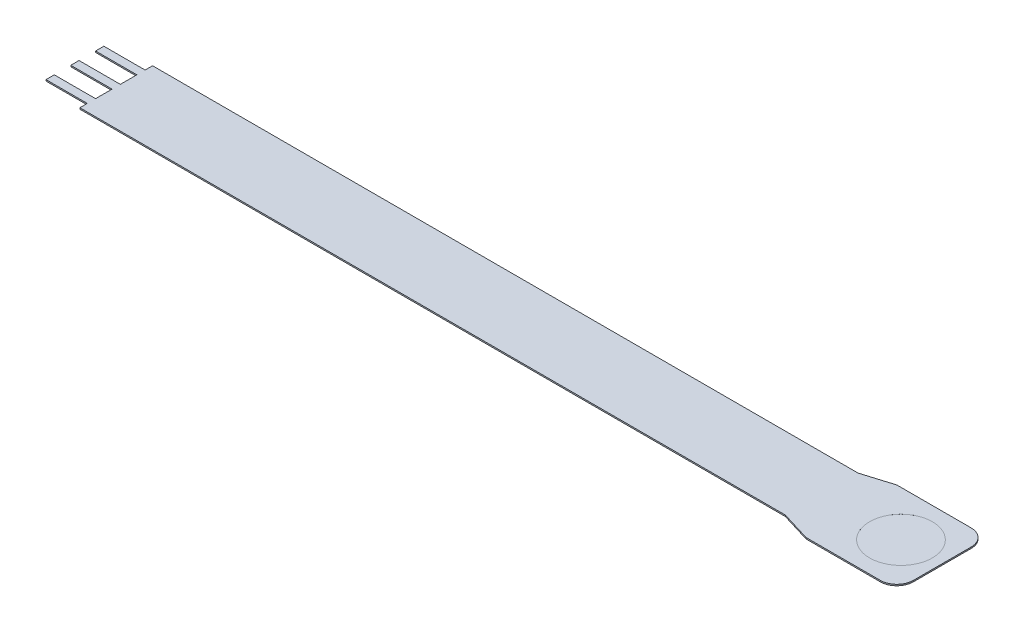
from build123d import *

# Parameters (mm, degrees)
BOSS_EXTRUDE1_DEPTH = 0.2032
SKETCH2_R           = 4.826
CUT_EXTRUDE1_DEPTH  = 0.00254
FILLET1_R           = 2.54


with BuildPart() as part:
    # Sketch1 → Boss-Extrude1 (new body)
    with BuildSketch(Plane(origin=(0, 0, 0), x_dir=(1, 0, 0), z_dir=(0, 1, 0))):
        Polygon((-120.65, -0.635), (-127, -0.635), (-127, 0.635), (-120.65, 0.635), (-120.65, 3.175), (-127, 3.175), (-127, 4.445), (-120.65, 4.445), (-120.65, 5.588), (-108.748705113, 5.588), (-12.192, 5.588), (-7.62, 6.985), (6.35, 6.985), (6.35, -6.985), (-7.62, -6.985), (-12.192, -5.588), (-108.748705113, -5.588), (-120.65, -5.588), (-120.65, -4.445), (-127, -4.445), (-127, -3.175), (-120.65, -3.175), align=None)
    extrude(amount=BOSS_EXTRUDE1_DEPTH)

    # Sketch2 → Cut-Extrude1 (cut)
    with BuildSketch(Plane(origin=(0, 0.2032, 0), x_dir=(1, 0, 0), z_dir=(0, 1, 0))):
        Circle(SKETCH2_R)
    extrude(amount=-CUT_EXTRUDE1_DEPTH, mode=Mode.SUBTRACT)

    # Fillet1
    fillet1_edges = [part.edges().sort_by_distance(p)[0] for p in [
        (6.35, 0.1016, -6.985),
        (6.35, 0.1016, 6.985),
    ]]
    fillet(fillet1_edges, radius=FILLET1_R)


solid = part.part
